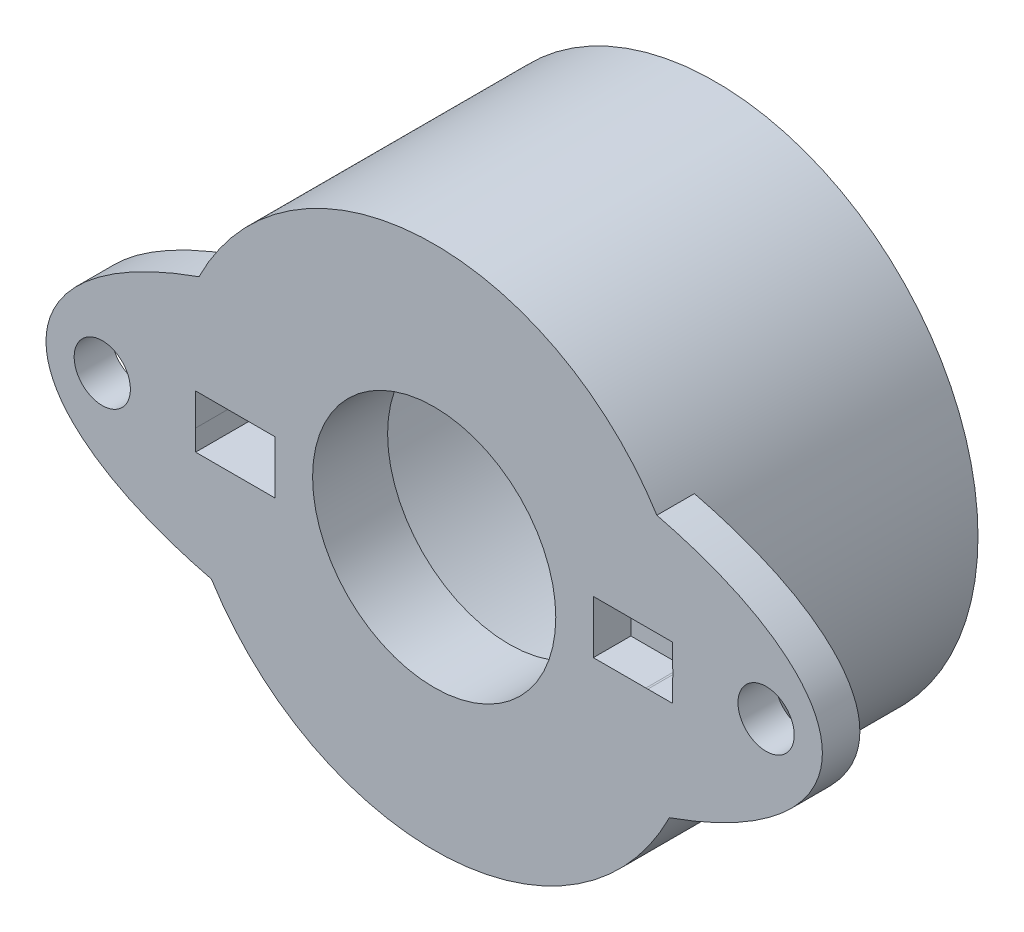
from build123d import *

# Parameters (mm, degrees)
IZIM7_R                     = 14
Y_KSEKLIK_EKSTR_ZYON3_DEPTH = 15
IZIM8_R                     = 12.75
KES_EKSTR_ZYON2_DEPTH       = 13
IZIM10_RX                   = 20.721224891
IZIM10_RY                   = 8.451844087
Y_KSEKLIK_EKSTR_ZYON5_DEPTH = 2
IZIM11_R                    = 1.5
KES_EKSTR_ZYON4_DEPTH       = 12
IZIM12_R                    = 1.39637185
KES_EKSTR_ZYON5_DEPTH       = 12
IZIM13_R                    = 1.39637185
KES_EKSTR_ZYON9_DEPTH       = 10
IZIM17_R                    = 6.48453934
KES_EKSTR_ZYON10_DEPTH      = 10
IZIM18_R                    = 12.75
Y_KSEKLIK_EKSTR_ZYON6_DEPTH = 2
IZIM19_R                    = 6.48453934
KES_EKSTR_ZYON11_DEPTH      = 15
IZIM20_W                    = 4.233334515
IZIM20_H                    = 2.828390799
KES_EKSTR_ZYON12_DEPTH      = 15


with BuildPart() as part:
    # Çizim7 → Yükseklik-Ekstrüzyon3 (new body)
    with BuildSketch(Plane.XY):
        Circle(IZIM7_R)
    extrude(amount=Y_KSEKLIK_EKSTR_ZYON3_DEPTH)

    # Çizim8 → Kes-Ekstrüzyon2 (cut)
    with BuildSketch(Plane(origin=(0, 0, 0), x_dir=(-1, 0, 0), z_dir=(0, 0, -1))):
        Circle(IZIM8_R)
    extrude(amount=-KES_EKSTR_ZYON2_DEPTH, mode=Mode.SUBTRACT)

    # Çizim10 → Yükseklik-Ekstrüzyon5 (add)
    with BuildSketch(Plane.XY.offset(15)):
        with Locations(Location((0, 0), (0, 0, -177.201101486))):
            Ellipse(IZIM10_RX, IZIM10_RY)
    extrude(amount=-Y_KSEKLIK_EKSTR_ZYON5_DEPTH)

    # Çizim11 → Kes-Ekstrüzyon4 (cut)
    with BuildSketch(Plane(origin=(0, 0, 13), x_dir=(-1, 0, 0), z_dir=(0, 0, -1))):
        with Locations((-17.700084822, 0.922540909)):
            Circle(IZIM11_R)
        with Locations((17.700084822, -0.808134051)):
            Circle(IZIM11_R)
    extrude(amount=-KES_EKSTR_ZYON4_DEPTH, mode=Mode.SUBTRACT)

    # Çizim12 → Kes-Ekstrüzyon5 (cut)
    with BuildSketch(Plane(origin=(0, 0, 13), x_dir=(-1, 0, 0), z_dir=(0, 0, -1))):
        with Locations((-11.340835644, 0.538812648)):
            Circle(IZIM12_R)
        with Locations((11.231387984, -0.55728261)):
            Circle(IZIM12_R)
    extrude(amount=-KES_EKSTR_ZYON5_DEPTH, mode=Mode.SUBTRACT)

    # Çizim13 → Kes-Ekstrüzyon9 (cut)
    with BuildSketch(Plane(origin=(0, 0, 13), x_dir=(-1, 0, 0), z_dir=(0, 0, -1))):
        with BuildLine():
            Line((8.487842828, 0.857001804), (8.487842828, -1.971567024))
            Line((8.487842828, -1.971567024), (12.596643341, -1.971567024))
            ThreePointArc((12.596643341, -1.971567024), (12.671184838, -1.415476879), (12.721189334, -0.856645746))
            Line((12.721189334, -0.856645746), (12.721189334, 0.857001804))
            Line((12.721189334, 0.857001804), (8.487842828, 0.857001804))
        make_face()
        with Locations((11.231387984, -0.55728261)):
            Circle(IZIM13_R, mode=Mode.SUBTRACT)
        with BuildLine():
            Line((-12.721189334, 0.327914487), (-12.721189334, -0.856645746))
            Line((-12.721189334, -0.856645746), (-11.391335286, -0.856645746))
            ThreePointArc((-11.391335286, -0.856645746), (-12.269614978, -0.503887353), (-12.721189334, 0.327914487))
        make_face()
        with BuildLine():
            Line((-12.721189334, 1.971923081), (-12.721189334, 0.749710808))
            ThreePointArc((-12.721189334, 0.749710808), (-10.298135643, 1.467591981), (-11.290336002, -0.856645746))
            Line((-11.290336002, -0.856645746), (-8.487842828, -0.856645746))
            Line((-8.487842828, -0.856645746), (-8.487842828, 1.971923081))
            Line((-8.487842828, 1.971923081), (-12.721189334, 1.971923081))
        make_face()
    extrude(amount=-KES_EKSTR_ZYON9_DEPTH, mode=Mode.SUBTRACT)

    # Çizim17 → Kes-Ekstrüzyon10 (cut)
    with BuildSketch(Plane(origin=(0, 0, 13), x_dir=(-1, 0, 0), z_dir=(0, 0, -1))):
        Circle(IZIM17_R)
    extrude(amount=-KES_EKSTR_ZYON10_DEPTH, mode=Mode.SUBTRACT)

    # Çizim18 → Yükseklik-Ekstrüzyon6 (add)
    with BuildSketch(Plane(origin=(0, 0, 13), x_dir=(-1, 0, 0), z_dir=(0, 0, -1))):
        Circle(IZIM18_R)
    extrude(amount=Y_KSEKLIK_EKSTR_ZYON6_DEPTH)

    # Çizim19 → Kes-Ekstrüzyon11 (cut)
    with BuildSketch(Plane.XY.offset(13)):
        Circle(IZIM19_R)
    extrude(amount=-KES_EKSTR_ZYON11_DEPTH, mode=Mode.SUBTRACT)

    # Çizim20 → Kes-Ekstrüzyon12 (cut)
    with BuildSketch(Plane.XY.offset(15)):
        with Locations((-10.604510085, -0.557371624)):
            Rectangle(IZIM20_W, IZIM20_H)
    extrude(amount=-KES_EKSTR_ZYON12_DEPTH, mode=Mode.SUBTRACT)


solid = part.part
